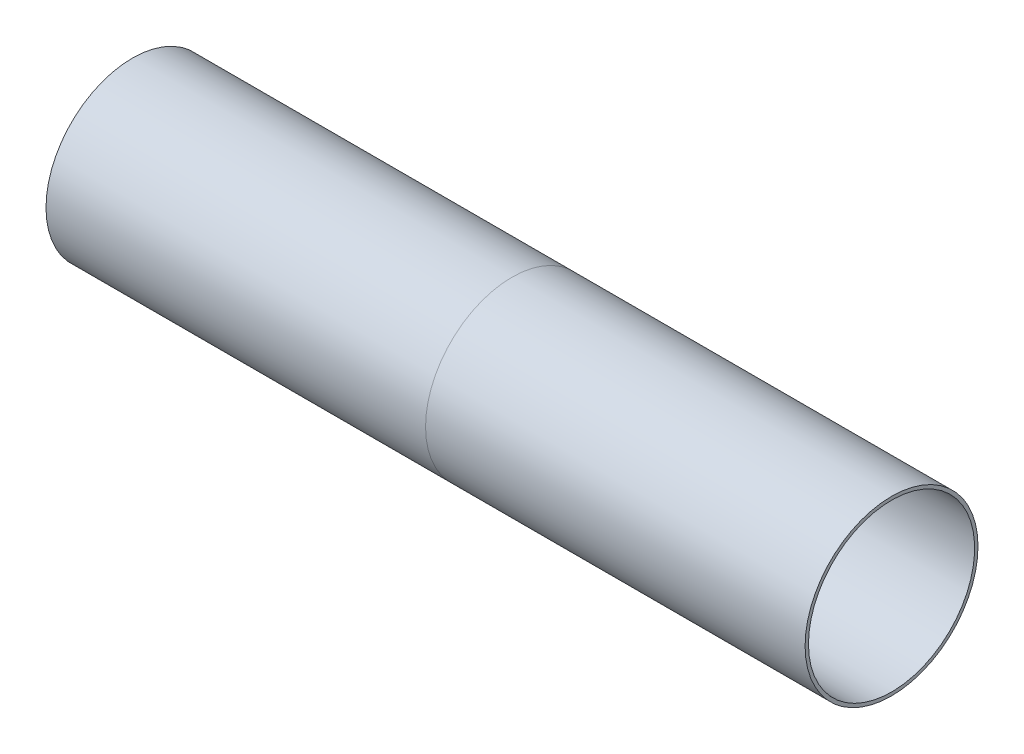
from build123d import *


with BuildPart() as part:
    # Sketch2 → Revolve1 (revolve)
    with BuildSketch(Plane(origin=(0, 0, 0), x_dir=(1, 0, 0), z_dir=(0, 1, 0))):
        Polygon((180, 39.4), (180, 41), (0, 41), (0, 39.4), (28.621705032, 37.9), (30.121705032, 39.4), align=None)
    revolve(axis=Axis((0, 0, 0), (1, 0, 0)))


with BuildPart() as body_2:
    # Sketch2_3 → Revolve2 (revolve)
    with BuildSketch(Plane(origin=(0, 0, 0), x_dir=(1, 0, 0), z_dir=(0, 1, 0))):
        Polygon((0, 39.4), (0, 41), (-180, 41), (-180, 39.4), (-151.378294968, 37.9), (-149.878294968, 39.4), (-30.121705032, 39.4), (-28.621705032, 37.9), align=None)
    revolve(axis=Axis((0, 0, 0), (1, 0, 0)))


with BuildPart() as body_3:
    # Sketch3 → Revolve3 (revolve)
    with BuildSketch(Plane(origin=(0, 0, 0), x_dir=(1, 0, 0), z_dir=(0, 1, 0))):
        Polygon((-28.621705032, 37.9), (0, 39.4), (28.621705032, 37.9), (28.621705032, 36.7), (-28.621705032, 36.7), align=None)
    revolve(axis=Axis((0, 0, 0), (1, 0, 0)))


solid = Compound([part.part, body_2.part, body_3.part])
